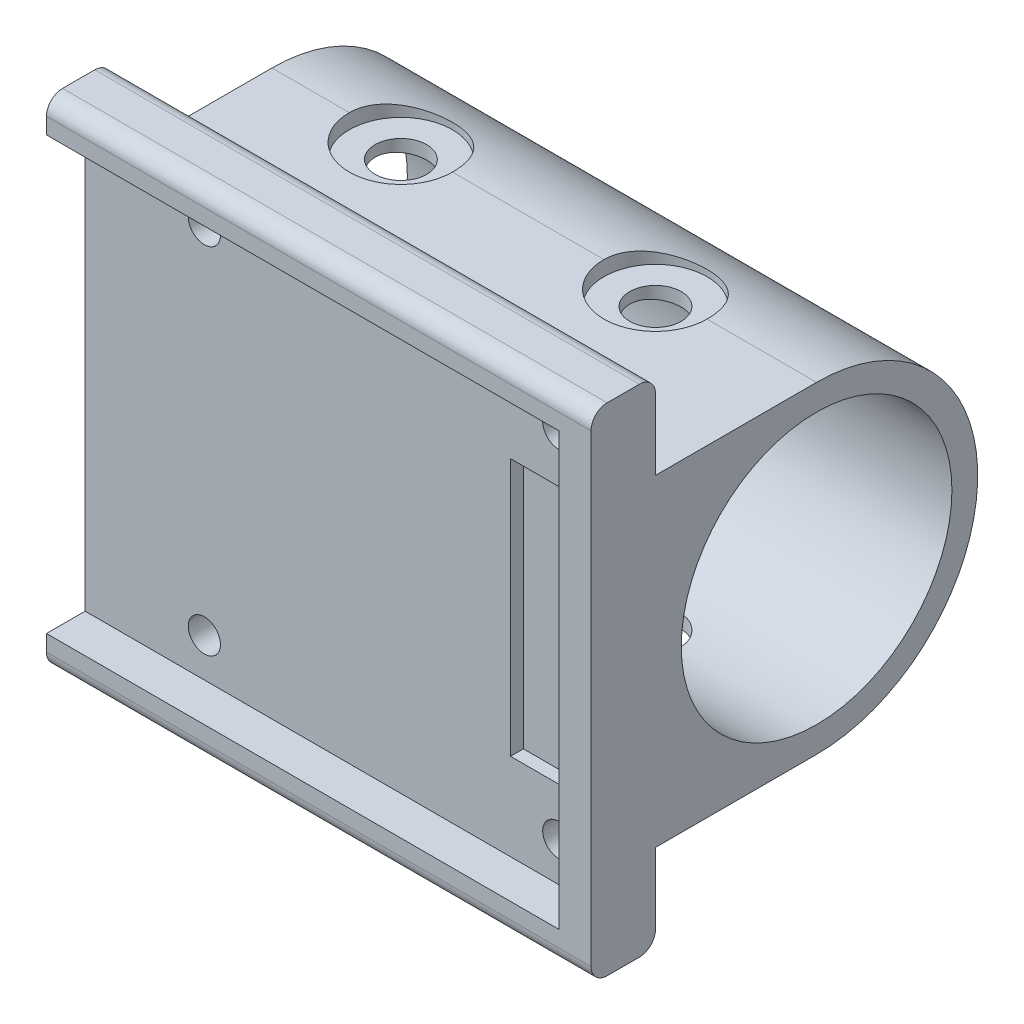
from build123d import *

# Parameters (mm, degrees)
SKETCH_1_W               = 31.8
SKETCH_1_H               = 26.8
SKETCH_1_R               = 1
EXTRUDE_1_DEPTH          = 1.6
EXTRUDE_2_DEPTH          = 4
SKETCH_2_W               = 5.4
SKETCH_2_H               = 16
CUT_EXTRUDE_1_DEPTH      = 0.8
EXTRUDE_3_DEPTH          = 33.8
SKETCH_4_R               = 1.6
CUT_EXTRUDE_2_DEPTH      = 31.944627967
CUT_EXTRUDE_2_DEPTH_BACK = 31.944627967
CUT_EXTRUDE_START        = -1
SKETCH_6_R               = 3.2
SKETCH_6_R_2             = 1.6
CUT_EXTRUDE_3_DEPTH      = 3
CUT_EXTRUDE_START_2      = 1.6
SKETCH_1_5_R             = 1
CUT_EXTRUDE_5_DEPTH      = 33.544628089
FILLET_1_R               = 1
SKETCH_7_R               = 1.5
SKETCH_7_R_2             = 1
CUT_EXTRUDE_6_DEPTH      = 0.8


with BuildPart() as part:
    # Эскиз1 → Бобышка-Вытянуть1 (new body)
    with BuildSketch(Plane.XY):
        Rectangle(SKETCH_1_W, SKETCH_1_H)
        with Locations((-8.5, -11)):
            Circle(SKETCH_1_R, mode=Mode.SUBTRACT)
        with Locations((-8.5, 11)):
            Circle(SKETCH_1_R, mode=Mode.SUBTRACT)
        with Locations((13.5, 11)):
            Circle(SKETCH_1_R, mode=Mode.SUBTRACT)
        with Locations((13.5, -11)):
            Circle(SKETCH_1_R, mode=Mode.SUBTRACT)
        with Locations((-8.5, 11)):
            Circle(SKETCH_1_R)
        with Locations((13.5, 11)):
            Circle(SKETCH_1_R)
        with Locations((-8.5, -11)):
            Circle(SKETCH_1_R)
        with Locations((13.5, -11)):
            Circle(SKETCH_1_R)
    extrude(amount=EXTRUDE_1_DEPTH)

    # Эскиз1<3> → Бобышка-Вытянуть2 (add)
    with BuildSketch(Plane.XY):
        Polygon((-15.9, -13.4), (-15.9, -15.4), (17.9, -15.4), (17.9, 15.4), (-15.9, 15.4), (-15.9, 13.4), (15.9, 13.4), (15.9, -13.4), align=None)
    extrude(amount=EXTRUDE_2_DEPTH)

    # Эскиз2 → Вырез-Вытянуть1 (cut)
    with BuildSketch(Plane.XY.offset(1.6)):
        with Locations((13.2, 0)):
            Rectangle(SKETCH_2_W, SKETCH_2_H)
    extrude(amount=-CUT_EXTRUDE_1_DEPTH, mode=Mode.SUBTRACT)

    # Эскиз3 → Бобышка-Вытянуть3 (add)
    with BuildSketch(Plane.ZY.offset(15.9)):
        with BuildLine():
            Line((-1.6, 0), (0, 0))
            ThreePointArc((0, 0), (-2.928932188, 7.071067812), (-10, 10))
            ThreePointArc((-10, 10), (-17.071067812, 7.071067812), (-20, 0))
            Line((-20, 0), (-18.4, 0))
            ThreePointArc((-18.4, 0), (-10, 8.4), (-1.6, 0))
        make_face()
        with BuildLine():
            ThreePointArc((-10, -10), (-2.928932188, -7.071067812), (0, 0))
            Line((0, 0), (-1.6, 0))
            ThreePointArc((-1.6, 0), (-10, -8.4), (-18.4, 0))
            Line((-18.4, 0), (-20, 0))
            ThreePointArc((-20, 0), (-17.071067812, -7.071067812), (-10, -10))
        make_face()
        with BuildLine():
            Line((0, -10), (0, 0))
            ThreePointArc((0, 0), (-2.928932188, -7.071067812), (-10, -10))
            Line((-10, -10), (0, -10))
        make_face()
        with BuildLine():
            ThreePointArc((-10, 10), (-2.928932188, 7.071067812), (0, 0))
            Line((0, 0), (0, 10))
            Line((0, 10), (-10, 10))
        make_face()
    extrude(amount=-EXTRUDE_3_DEPTH)

    # Эскиз4 → Вырез-Вытянуть2 (cut, two sides)
    with BuildSketch(Plane(origin=(0, 0, 0), x_dir=(1, 0, 0), z_dir=(0, 1, 0))) as cut_extrude_2_sk:
        with Locations(Location((-7.9, 10, 0), (0, 0, 270))):
            Circle(SKETCH_4_R)
        with Locations(Location((7.9, 10, 0), (0, 0, 270))):
            Circle(SKETCH_4_R)
    extrude(amount=CUT_EXTRUDE_2_DEPTH, mode=Mode.SUBTRACT)
    extrude(cut_extrude_2_sk.sketch, amount=-CUT_EXTRUDE_2_DEPTH_BACK, mode=Mode.SUBTRACT)

    # Эскиз6 → Вырез-Вытянуть3 (cut)
    with BuildSketch(Plane(origin=(0, 10.08, 0), x_dir=(1, 0, 0), z_dir=(0, 1, 0)).offset(CUT_EXTRUDE_START)):
        with Locations((7.9, 10)):
            Circle(SKETCH_6_R)
        with Locations(Location((7.9, 10, 0), (0, 0, 270))):
            Circle(SKETCH_6_R_2, mode=Mode.SUBTRACT)
        with Locations((-7.9, 10)):
            Circle(SKETCH_6_R)
        with Locations(Location((-7.9, 10, 0), (0, 0, 270))):
            Circle(SKETCH_6_R_2, mode=Mode.SUBTRACT)
    cut_extrude_3 = extrude(amount=CUT_EXTRUDE_3_DEPTH, mode=Mode.SUBTRACT)

    # Зеркальное отражение1: Вырез-Вытянуть3 across plane
    add(cut_extrude_3.mirror(Plane.ZX), mode=Mode.SUBTRACT)

    # Эскиз1<5> → Вырез-Вытянуть5 (cut, through all)
    with BuildSketch(Plane.XY.offset(CUT_EXTRUDE_START_2)):
        with Locations((13.5, 11)):
            Circle(SKETCH_1_5_R)
        with Locations((-8.5, 11)):
            Circle(SKETCH_1_5_R)
        with Locations((-8.5, -11)):
            Circle(SKETCH_1_5_R)
        with Locations((13.5, -11)):
            Circle(SKETCH_1_5_R)
    extrude(amount=-CUT_EXTRUDE_5_DEPTH, mode=Mode.SUBTRACT)

    # Скругление1
    fillet_1_edges = [part.edges().sort_by_distance(p)[0] for p in [
        (1, -15.4, 0),
        (1, 15.4, 4),
        (1, -15.4, 4),
        (1, 15.4, 0),
    ]]
    fillet(fillet_1_edges, radius=FILLET_1_R)

    # Эскиз7 → Вырез-Вытянуть6 (cut)
    with BuildSketch(Plane(origin=(0, 0, 0), x_dir=(-1, 0, 0), z_dir=(0, 0, -1))):
        with Locations((8.5, 11)):
            Circle(SKETCH_7_R)
        with Locations(Location((8.5, 11, 0), (0, 0, 180))):
            Circle(SKETCH_7_R_2, mode=Mode.SUBTRACT)
        with Locations((-13.5, 11)):
            Circle(SKETCH_7_R)
        with Locations(Location((-13.5, 11, 0), (0, 0, 180))):
            Circle(SKETCH_7_R_2, mode=Mode.SUBTRACT)
        with Locations((8.5, -11)):
            Circle(SKETCH_7_R)
        with Locations(Location((8.5, -11, 0), (0, 0, 180))):
            Circle(SKETCH_7_R_2, mode=Mode.SUBTRACT)
        with Locations((-13.5, -11)):
            Circle(SKETCH_7_R)
        with Locations(Location((-13.5, -11, 0), (0, 0, 180))):
            Circle(SKETCH_7_R_2, mode=Mode.SUBTRACT)
    extrude(amount=CUT_EXTRUDE_6_DEPTH, mode=Mode.SUBTRACT)


solid = part.part
